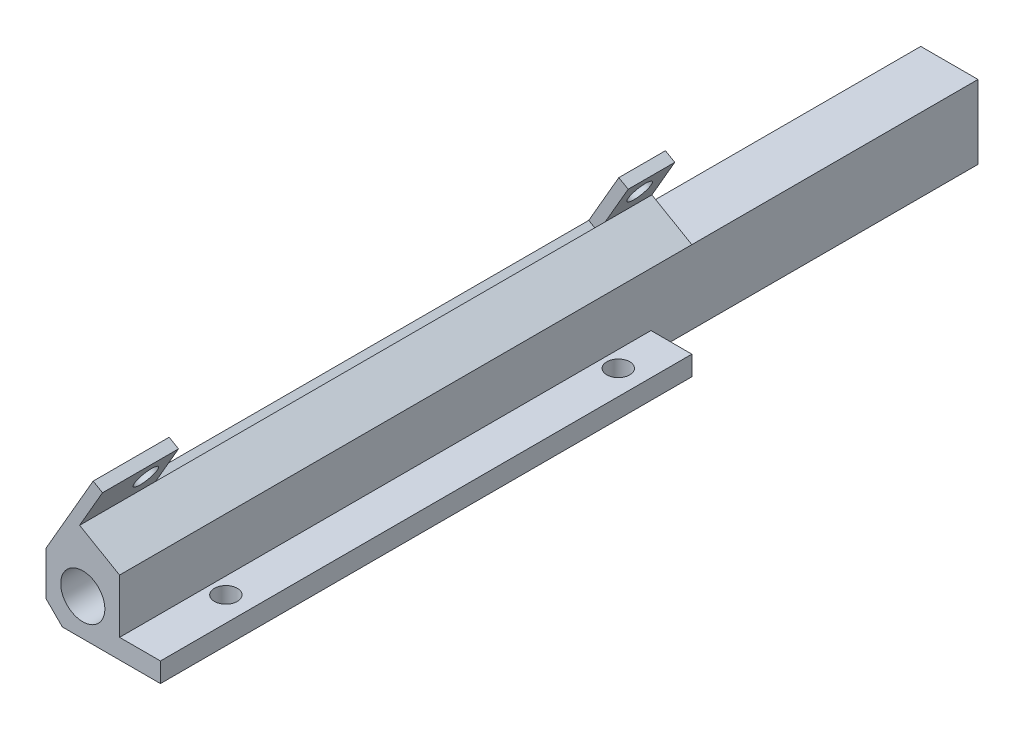
from build123d import *

# Parameters (mm, degrees)
SKETCH1_W           = 77.47
SKETCH1_H           = 133.35
BOSS_EXTRUDE1_DEPTH = 11.43
SKETCH2_R           = 3.429
CUT_EXTRUDE1_DEPTH  = 134.35
CUT_EXTRUDE2_DEPTH  = 12.43
SKETCH4_W           = 54.61
SKETCH4_H           = 6.35
CUT_EXTRUDE3_DEPTH  = 134.35
CHAMFER1_SIZE       = 2.54
CUT_EXTRUDE4_DEPTH  = 12.43
SKETCH6_W           = 53.34
SKETCH6_H           = 82.55
CUT_EXTRUDE5_DEPTH  = 12.43
SKETCH7_R           = 1.778
HOLE_CUTS_1_DEPTH   = 6.08
BOSS_EXTRUDE5_DEPTH = 88.9
SKETCH18_W          = 6.35
SKETCH18_H          = 5.08
CUT_EXTRUDE13_DEPTH = 76.2
HOLE_CUTS_2_REACH   = 10.608
SKETCH19_R          = 1.778
SKETCH20_W          = 88.9
SKETCH20_H          = 11.176
CUT_EXTRUDE16_DEPTH = 1.27
CUT_EXTRUDE22_DEPTH = 134.35
SKETCH22_W          = 6.35
SKETCH22_H          = 82.55
CUT_EXTRUDE18_DEPTH = 2.032
SKETCH23_W          = 1.676805636
SKETCH23_H          = 88.9
BOSS_EXTRUDE6_DEPTH = 1.27
CUT_EXTRUDE19_REACH = 10.019
SKETCH24_W          = 69.85
SKETCH24_H          = 9.3345
CUT_EXTRUDE20_REACH = 12.28
SKETCH25_W          = 1.27
SKETCH25_H          = 88.9
CUT_EXTRUDE21_REACH = 7.08
SKETCH26_W          = 6.35
SKETCH26_H          = 6.35


with BuildPart() as part:
    # Sketch1 → Boss-Extrude1 (new body)
    with BuildSketch(Plane(origin=(0, 0, 0), x_dir=(1, 0, 0), z_dir=(0, 1, 0))):
        with Locations((38.735, 66.675)):
            Rectangle(SKETCH1_W, SKETCH1_H)
    extrude(amount=BOSS_EXTRUDE1_DEPTH)

    # Sketch2 → Cut-Extrude1 (cut, through all)
    with BuildSketch(Plane.XY):
        with Locations((5.715, 5.715)):
            Circle(SKETCH2_R)
        with Locations((71.755, 5.715)):
            Circle(SKETCH2_R)
    extrude(amount=-CUT_EXTRUDE1_DEPTH, mode=Mode.SUBTRACT)

    # Sketch3 → Cut-Extrude2 (cut, through all)
    with BuildSketch(Plane(origin=(0, 11.43, 0), x_dir=(1, 0, 0), z_dir=(0, 1, 0))):
        with BuildLine():
            Line((11.43, 133.35), (11.43, 95.25))
            ThreePointArc((11.43, 95.25), (15.149743879, 86.269743879), (24.13, 82.55))
            Line((24.13, 82.55), (53.34, 82.55))
            ThreePointArc((53.34, 82.55), (62.320256121, 86.269743879), (66.04, 95.25))
            Line((66.04, 95.25), (66.04, 133.35))
            Line((66.04, 133.35), (11.43, 133.35))
        make_face()
    extrude(amount=-CUT_EXTRUDE2_DEPTH, mode=Mode.SUBTRACT)

    # Sketch4 → Cut-Extrude3 (cut, through all)
    with BuildSketch(Plane(origin=(0, 0, -133.35), x_dir=(-1, 0, 0), z_dir=(0, 0, -1))):
        with Locations((-38.735, 8.255)):
            Rectangle(SKETCH4_W, SKETCH4_H)
    extrude(amount=-CUT_EXTRUDE3_DEPTH, mode=Mode.SUBTRACT)

    # Chamfer1
    chamfer1_edges = [part.edges().sort_by_distance(p)[0] for p in [
        (77.47, 11.43, -66.675),
        (0, 11.43, -66.675),
        (77.47, 0, -66.675),
        (0, 0, -66.675),
    ]]
    chamfer(chamfer1_edges, length=CHAMFER1_SIZE)

    # Sketch5 → Cut-Extrude4 (cut, through all)
    with BuildSketch(Plane(origin=(0, 11.43, 0), x_dir=(1, 0, 0), z_dir=(0, 1, 0))):
        Polygon((11.43, 95.25), (11.43, 82.55), (77.47, 82.55), (77.47, 133.35), (11.43, 133.35), align=None)
    extrude(amount=-CUT_EXTRUDE4_DEPTH, mode=Mode.SUBTRACT)

    # Sketch6 → Cut-Extrude5 (cut, through all)
    with BuildSketch(Plane(origin=(0, 11.43, 0), x_dir=(1, 0, 0), z_dir=(0, 1, 0))):
        with Locations((50.8, 41.275)):
            Rectangle(SKETCH6_W, SKETCH6_H)
    extrude(amount=-CUT_EXTRUDE5_DEPTH, mode=Mode.SUBTRACT)

    # Sketch7 → Hole Cuts 1 (cut, through all)
    with BuildSketch(Plane(origin=(0, 5.08, 0), x_dir=(1, 0, 0), z_dir=(0, 1, 0))):
        with Locations((13.97, 74.93)):
            Circle(SKETCH7_R)
        with Locations((13.97, 13.97)):
            Circle(SKETCH7_R)
    extrude(amount=-HOLE_CUTS_1_DEPTH, mode=Mode.SUBTRACT)

    # Sketch17 → Boss-Extrude5 (add)
    with BuildSketch(Plane.XY):
        Polygon((0, 8.89), (0, 11.869940905), (5.588, 21.548640818), (8.851738686, 19.664320409), (5.930738686, 14.605), (11.43, 11.43), (2.54, 11.43), align=None)
    extrude(amount=-BOSS_EXTRUDE5_DEPTH)

    # Sketch18 → Cut-Extrude13 (cut)
    with BuildSketch(Plane.XY):
        with Locations((20.955, 2.54)):
            Rectangle(SKETCH18_W, SKETCH18_H)
    extrude(amount=-CUT_EXTRUDE13_DEPTH, mode=Mode.SUBTRACT)

    # Sketch19 → Hole Cuts 2 (cut, up to next)
    with BuildSketch(Plane(origin=(-1.876096497, 1.083164817, 0), x_dir=(0, 0, -1), z_dir=(0.866025404, -0.5, 0)), mode=Mode.PRIVATE) as hole_cuts_2_sk1:
        with Locations((8.382, 19.423670365)):
            Circle(SKETCH19_R)
    hole_cuts_2_tool1 = extrude(hole_cuts_2_sk1.sketch, amount=-HOLE_CUTS_2_REACH, mode=Mode.PRIVATE) & part.part
    add(hole_cuts_2_tool1.solids().sort_by_distance((7.835739, 17.904557, -8.382))[0], mode=Mode.SUBTRACT)
    # Sketch19 → Hole Cuts 2 (cut, up to next)
    with BuildSketch(Plane(origin=(-1.876096497, 1.083164817, 0), x_dir=(0, 0, -1), z_dir=(0.866025404, -0.5, 0)), mode=Mode.PRIVATE) as hole_cuts_2_sk2:
        with Locations((85.09, 19.423670365)):
            Circle(SKETCH19_R)
    hole_cuts_2_tool2 = extrude(hole_cuts_2_sk2.sketch, amount=-HOLE_CUTS_2_REACH, mode=Mode.PRIVATE) & part.part
    add(hole_cuts_2_tool2.solids().sort_by_distance((7.835739, 17.904557, -85.09))[0], mode=Mode.SUBTRACT)

    # Sketch20 → Cut-Extrude16 (cut)
    with BuildSketch(Plane(origin=(-5.139835183, 2.967485226, 0), x_dir=(0, 0, 1), z_dir=(-0.866025404, 0.5, 0))):
        with Locations((-44.45, 15.867670365)):
            Rectangle(SKETCH20_W, SKETCH20_H)
    extrude(amount=-CUT_EXTRUDE16_DEPTH, mode=Mode.SUBTRACT)

    # Sketch31 → Cut-Extrude22 (cut, through all)
    with BuildSketch(Plane.XY):
        Polygon((8.14000854, 20.075238), (12.539417591, 17.535238), (9.618417591, 12.475917591), (5.21900854, 15.015917591), align=None)
    extrude(amount=-CUT_EXTRUDE22_DEPTH, mode=Mode.SUBTRACT)

    # Sketch22 → Cut-Extrude18 (cut)
    with BuildSketch(Plane(origin=(0, 5.08, 0), x_dir=(1, 0, 0), z_dir=(0, 1, 0))):
        with Locations((14.605, 41.275)):
            Rectangle(SKETCH22_W, SKETCH22_H)
    extrude(amount=-CUT_EXTRUDE18_DEPTH, mode=Mode.SUBTRACT)

    # Sketch23 → Boss-Extrude6 (add)
    with BuildSketch(Plane(origin=(10.727835183, 18.581155592, 0), x_dir=(0.866025404, -0.5, 0), z_dir=(0.5, 0.866025404, 0))):
        with Locations((-3.826567635, 44.45)):
            Rectangle(SKETCH23_W, SKETCH23_H)
    extrude(amount=BOSS_EXTRUDE6_DEPTH)

    # Sketch24 → Cut-Extrude19 (cut, up to next)
    with BuildSketch(Plane(origin=(-2.587826643, 1.494082409, 0), x_dir=(0, 0, -1), z_dir=(0.866025404, -0.5, 0)), mode=Mode.PRIVATE) as cut_extrude19_sk1:
        with Locations((46.736, 18.058420365)):
            Rectangle(SKETCH24_W, SKETCH24_H)
    cut_extrude19_tool1 = extrude(cut_extrude19_sk1.sketch, amount=-CUT_EXTRUDE19_REACH, mode=Mode.PRIVATE) & part.part
    add(cut_extrude19_tool1.solids().sort_by_distance((6.441384, 17.133133, -46.736))[0], mode=Mode.SUBTRACT)

    # Sketch25 → Cut-Extrude20 (cut, up to next)
    with BuildSketch(Plane(origin=(5.139835183, 8.902455679, 0), x_dir=(0.866025404, -0.5, 0), z_dir=(0.5, 0.866025404, 0)), mode=Mode.PRIVATE) as cut_extrude20_sk1:
        with Locations((-5.299970453, 44.45)):
            Rectangle(SKETCH25_W, SKETCH25_H)
    cut_extrude20_tool1 = extrude(cut_extrude20_sk1.sketch, amount=-CUT_EXTRUDE20_REACH, mode=Mode.PRIVATE) & part.part
    add(cut_extrude20_tool1.solids().sort_by_distance((0.549926, 11.552441, -44.45))[0], mode=Mode.SUBTRACT)

    # Sketch26 → Cut-Extrude21 (cut, up to next)
    with BuildSketch(Plane(origin=(0, 5.08, 0), x_dir=(1, 0, 0), z_dir=(0, 1, 0)), mode=Mode.PRIVATE) as cut_extrude21_sk1:
        with Locations((20.955, 79.375)):
            Rectangle(SKETCH26_W, SKETCH26_H)
    cut_extrude21_tool1 = extrude(cut_extrude21_sk1.sketch, amount=-CUT_EXTRUDE21_REACH, mode=Mode.PRIVATE) & part.part
    add(cut_extrude21_tool1.solids().sort_by_distance((20.955, 5.08, -79.375))[0], mode=Mode.SUBTRACT)


solid = part.part
